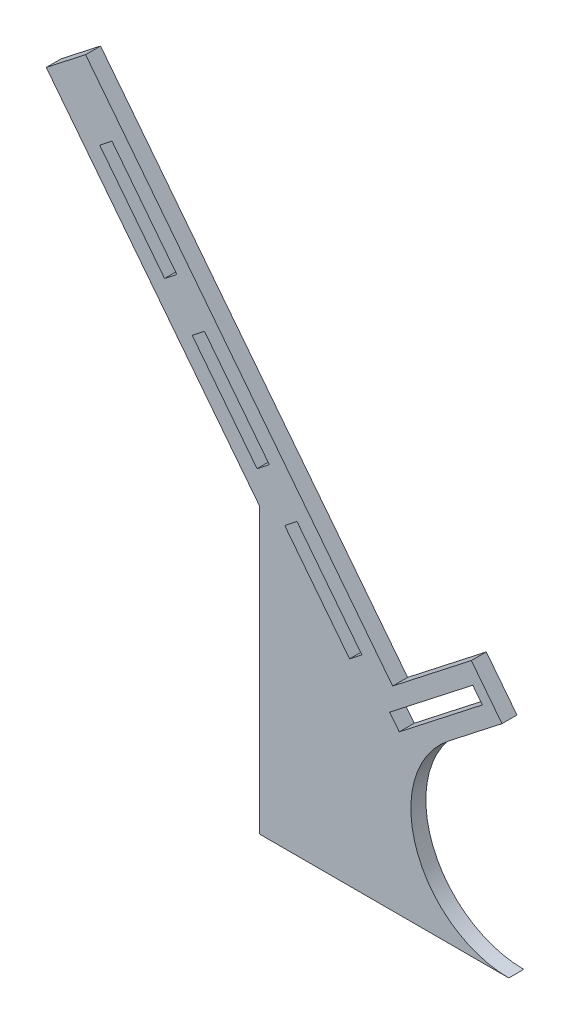
from build123d import *

# Parameters (mm, degrees)
SALIENTE_EXTRUIR1_DEPTH = 3
CORTAR_EXTRUIR2_DEPTH   = 4
MATRIZL2_COUNT          = 3
MATRIZL2_PITCH          = 30.123
SALIENTE_EXTRUIR2_DEPTH = 3


with BuildPart() as part:
    # Croquis1 → Saliente-Extruir1 (new body)
    with BuildSketch(Plane.XY):
        Polygon((0, 25), (-67.699475396, 111.699371573), (-59.817714344, 117.853869336), (1.727263289, 39.036258815), (17.490785393, 51.345254342), (23.645283156, 43.46349329), align=None)
    extrude(amount=SALIENTE_EXTRUIR1_DEPTH)

    # Croquis3 → Cortar-Extruir2 (cut, through all)
    with BuildSketch(Plane.XY.offset(3)):
        Polygon((-41.526865164, 88.842712042), (-54.52701079, 105.491355912), (-56.988484766, 103.569306261), (-43.988339141, 86.920662391), align=None)
        Polygon((3.054211194, 31.74749407), (19.702855065, 44.747639696), (17.780805413, 47.209113672), (1.132161543, 34.208968047), align=None)
    cortar_extruir2 = extrude(amount=-CORTAR_EXTRUIR2_DEPTH, mode=Mode.SUBTRACT)

    # MatrizL2: Cortar-Extruir2 ×3
    with Locations(*[Vector(0.615449776, -0.788176105, 0) * (i * MATRIZL2_PITCH) for i in range(1, MATRIZL2_COUNT)]):
        add(cortar_extruir2, mode=Mode.SUBTRACT)

    # Croquis1_4 → Saliente-Extruir2 (add)
    with BuildSketch(Plane.XY):
        with BuildLine():
            Line((12.922592854, 35.090647038), (0, 25))
            Line((0, 25), (-25, 57.016264183))
            Line((-25, 57.016264183), (-25, 0))
            Line((-25, 0), (25, 0))
            ThreePointArc((25, 0), (6.444560953, 13.237346231), (12.922592854, 35.090647038))
        make_face()
    extrude(amount=SALIENTE_EXTRUIR2_DEPTH)


solid = part.part
